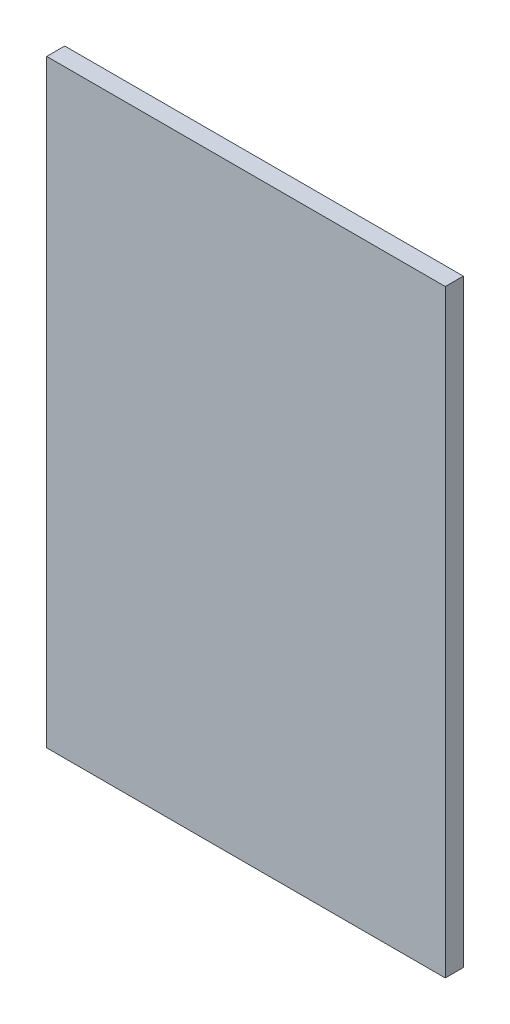
from build123d import *

# Parameters (mm, degrees)
SKETCH1_W           = 398
SKETCH1_H           = 598
BOSS_EXTRUDE1_DEPTH = 18


with BuildPart() as part:
    # Sketch1 → Boss-Extrude1 (new body)
    with BuildSketch(Plane.XY):
        Rectangle(SKETCH1_W, SKETCH1_H)
    extrude(amount=BOSS_EXTRUDE1_DEPTH)


solid = part.part
